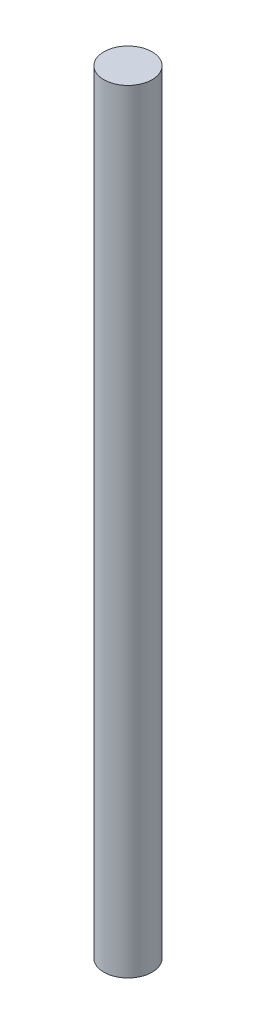
from build123d import *

# Parameters (mm, degrees)
SKETCH1_R           = 2.38125
BOSS_EXTRUDE1_DEPTH = 76.2


with BuildPart() as part:
    # Sketch1 → Boss-Extrude1 (new body)
    with BuildSketch(Plane(origin=(0, 0, 0), x_dir=(1, 0, 0), z_dir=(0, 1, 0))):
        Circle(SKETCH1_R)
    extrude(amount=BOSS_EXTRUDE1_DEPTH)


solid = part.part
